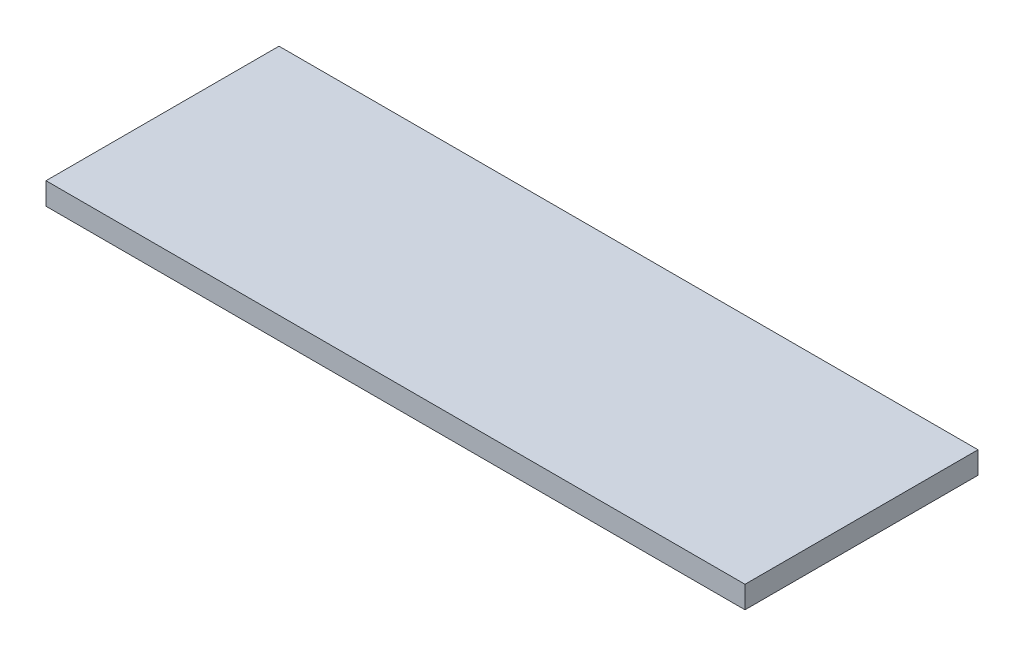
from build123d import *

# Parameters (mm, degrees)
SKETCH1_W           = 60
SKETCH1_H           = 20
BOSS_EXTRUDE1_DEPTH = 1.9


with BuildPart() as part:
    # Sketch1 → Boss-Extrude1 (new body)
    with BuildSketch(Plane(origin=(0, 0, 0), x_dir=(1, 0, 0), z_dir=(0, 1, 0))):
        Rectangle(SKETCH1_W, SKETCH1_H)
    extrude(amount=BOSS_EXTRUDE1_DEPTH)


solid = part.part
